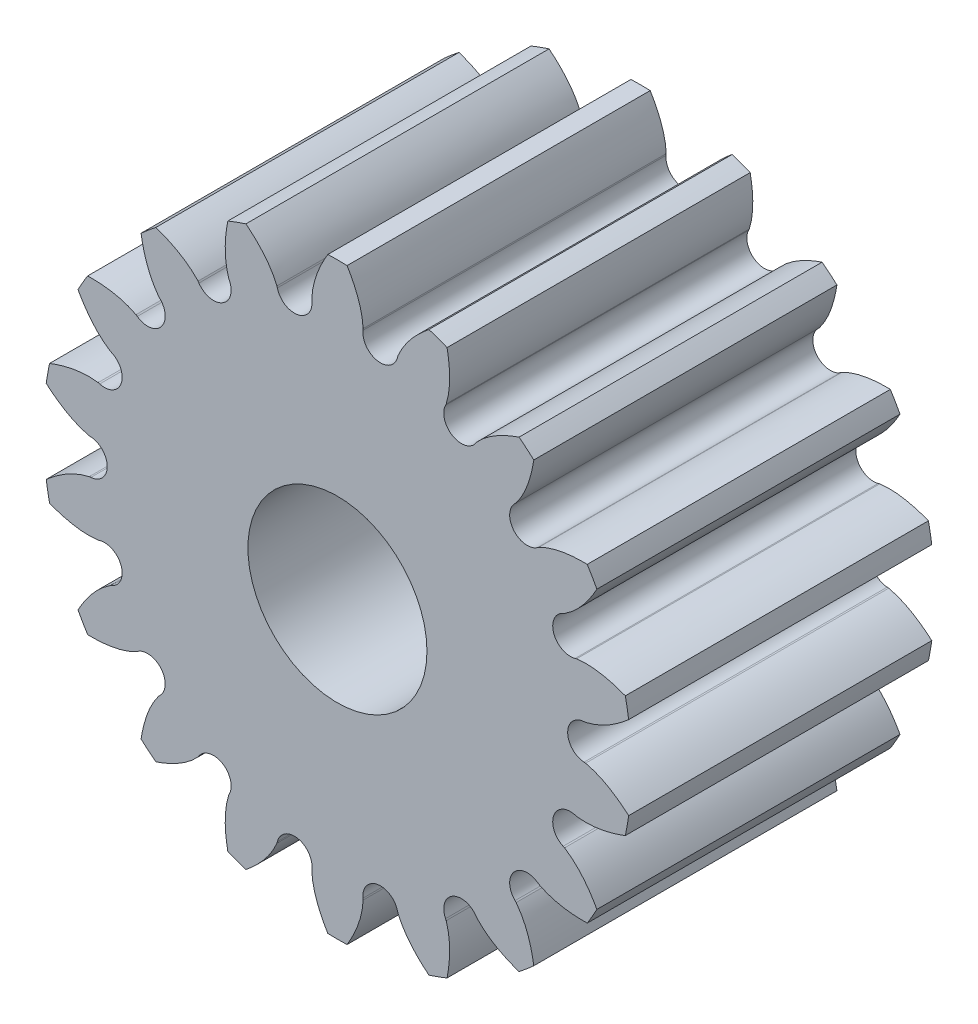
from build123d import *

# Parameters (mm, degrees)
SKETCH3_R                      = 2.286
SKETCH3_R_2                    = 0.889
BASE_DEPTH                     = 3.0099
HALF_TOOTH_DEPTH               = 3.0099
PATTERN_OF_TOOTH_COUNT         = 18
PATTERN_OF_TOOTH_COPY_1_DEPTH  = 3.0099
PATTERN_OF_TOOTH_COPY_2_DEPTH  = 3.0099
PATTERN_OF_TOOTH_COPY_3_DEPTH  = 3.0099
PATTERN_OF_TOOTH_COPY_4_DEPTH  = 3.0099
PATTERN_OF_TOOTH_COPY_5_DEPTH  = 3.0099
PATTERN_OF_TOOTH_COPY_6_DEPTH  = 3.0099
PATTERN_OF_TOOTH_COPY_7_DEPTH  = 3.0099
PATTERN_OF_TOOTH_COPY_8_DEPTH  = 3.0099
PATTERN_OF_TOOTH_COPY_9_DEPTH  = 3.0099
PATTERN_OF_TOOTH_COPY_10_DEPTH = 3.0099
PATTERN_OF_TOOTH_COPY_11_DEPTH = 3.0099
PATTERN_OF_TOOTH_COPY_12_DEPTH = 3.0099
PATTERN_OF_TOOTH_COPY_13_DEPTH = 3.0099
PATTERN_OF_TOOTH_COPY_14_DEPTH = 3.0099
PATTERN_OF_TOOTH_COPY_15_DEPTH = 3.0099
PATTERN_OF_TOOTH_COPY_16_DEPTH = 3.0099
PATTERN_OF_TOOTH_COPY_17_DEPTH = 3.0099


with BuildPart() as part:
    # Sketch3 → Base (new body)
    with BuildSketch(Plane.XY):
        Circle(SKETCH3_R)
        Circle(SKETCH3_R_2, mode=Mode.SUBTRACT)
    extrude(amount=BASE_DEPTH)

    # Sketch2 → Half tooth (add)
    with BuildSketch(Plane.XY):
        with BuildLine():
            Line((0, 2.921), (0, 2.286))
            ThreePointArc((0, 2.286), (0.199238028, 2.27730108), (0.396959734, 2.251270523))
            ThreePointArc((0.396959734, 2.251270523), (0.28773176, 2.318156306), (0.253382626, 2.441544292))
            Line((0.253382626, 2.441544292), (0.255003353, 2.457161288))
            add(Edge.make_bspline(
                [(0.255003353, 2.457161288), (0.25245669, 2.511970923), (0.22493294, 2.674677864), (0.152013752, 2.825486334), (0.095650308, 2.91943351)],
                knots=[0, 0, 0, 0, 0.332628043, 1, 1, 1, 1], degree=3))
            ThreePointArc((0.095650308, 2.91943351), (0.047831567, 2.920608351), (0, 2.921))
        make_face()
    half_tooth = extrude(amount=HALF_TOOTH_DEPTH)

    # Mirror of half tooth: Half tooth across plane
    add(half_tooth.mirror(Plane.ZY))

    # Pattern of tooth: Half tooth ×18 about axis
    pattern_of_tooth_axis = Axis((0, 0, 3.0099), (0, 0, 1))
    for i in range(1, PATTERN_OF_TOOTH_COUNT):
        add(half_tooth.rotate(pattern_of_tooth_axis, i * 360 / PATTERN_OF_TOOTH_COUNT))

    # Pattern of tooth copy 1 sketch → Pattern of tooth copy 1 (add)
    with BuildSketch(Plane(origin=(0, 0, 0), x_dir=(-0.939692621, -0.342020143, 0), z_dir=(0, 0, 1))):
        with BuildLine():
            Line((0, -2.921), (0, -2.286))
            ThreePointArc((0, -2.286), (0.199238028, -2.27730108), (0.396959734, -2.251270523))
            ThreePointArc((0.396959734, -2.251270523), (0.28773176, -2.318156306), (0.253382626, -2.441544292))
            Line((0.253382626, -2.441544292), (0.255003353, -2.457161288))
            add(Edge.make_bspline(
                [(0.255003353, -2.457161288), (0.25245669, -2.511970923), (0.22493294, -2.674677864), (0.152013752, -2.825486334), (0.095650308, -2.91943351)],
                knots=[0, 0, 0, 0, 0.332628043, 1, 1, 1, 1], degree=3))
            ThreePointArc((0.095650308, -2.91943351), (0.047831567, -2.920608351), (0, -2.921))
        make_face()
    extrude(amount=PATTERN_OF_TOOTH_COPY_1_DEPTH)

    # Pattern of tooth copy 2 sketch → Pattern of tooth copy 2 (add)
    with BuildSketch(Plane(origin=(0, 0, 0), x_dir=(-0.766044443, -0.64278761, 0), z_dir=(0, 0, 1))):
        with BuildLine():
            Line((0, -2.921), (0, -2.286))
            ThreePointArc((0, -2.286), (0.199238028, -2.27730108), (0.396959734, -2.251270523))
            ThreePointArc((0.396959734, -2.251270523), (0.28773176, -2.318156306), (0.253382626, -2.441544292))
            Line((0.253382626, -2.441544292), (0.255003353, -2.457161288))
            add(Edge.make_bspline(
                [(0.255003353, -2.457161288), (0.25245669, -2.511970923), (0.22493294, -2.674677864), (0.152013752, -2.825486334), (0.095650308, -2.91943351)],
                knots=[0, 0, 0, 0, 0.332628043, 1, 1, 1, 1], degree=3))
            ThreePointArc((0.095650308, -2.91943351), (0.047831567, -2.920608351), (0, -2.921))
        make_face()
    extrude(amount=PATTERN_OF_TOOTH_COPY_2_DEPTH)

    # Pattern of tooth copy 3 sketch → Pattern of tooth copy 3 (add)
    with BuildSketch(Plane(origin=(0, 0, 0), x_dir=(-0.5, -0.866025404, 0), z_dir=(0, 0, 1))):
        with BuildLine():
            Line((0, -2.921), (0, -2.286))
            ThreePointArc((0, -2.286), (0.199238028, -2.27730108), (0.396959734, -2.251270523))
            ThreePointArc((0.396959734, -2.251270523), (0.28773176, -2.318156306), (0.253382626, -2.441544292))
            Line((0.253382626, -2.441544292), (0.255003353, -2.457161288))
            add(Edge.make_bspline(
                [(0.255003353, -2.457161288), (0.25245669, -2.511970923), (0.22493294, -2.674677864), (0.152013752, -2.825486334), (0.095650308, -2.91943351)],
                knots=[0, 0, 0, 0, 0.332628043, 1, 1, 1, 1], degree=3))
            ThreePointArc((0.095650308, -2.91943351), (0.047831567, -2.920608351), (0, -2.921))
        make_face()
    extrude(amount=PATTERN_OF_TOOTH_COPY_3_DEPTH)

    # Pattern of tooth copy 4 sketch → Pattern of tooth copy 4 (add)
    with BuildSketch(Plane(origin=(0, 0, 0), x_dir=(-0.173648178, -0.984807753, 0), z_dir=(0, 0, 1))):
        with BuildLine():
            Line((0, -2.921), (0, -2.286))
            ThreePointArc((0, -2.286), (0.199238028, -2.27730108), (0.396959734, -2.251270523))
            ThreePointArc((0.396959734, -2.251270523), (0.28773176, -2.318156306), (0.253382626, -2.441544292))
            Line((0.253382626, -2.441544292), (0.255003353, -2.457161288))
            add(Edge.make_bspline(
                [(0.255003353, -2.457161288), (0.25245669, -2.511970923), (0.22493294, -2.674677864), (0.152013752, -2.825486334), (0.095650308, -2.91943351)],
                knots=[0, 0, 0, 0, 0.332628043, 1, 1, 1, 1], degree=3))
            ThreePointArc((0.095650308, -2.91943351), (0.047831567, -2.920608351), (0, -2.921))
        make_face()
    extrude(amount=PATTERN_OF_TOOTH_COPY_4_DEPTH)

    # Pattern of tooth copy 5 sketch → Pattern of tooth copy 5 (add)
    with BuildSketch(Plane(origin=(0, 0, 0), x_dir=(0.173648178, -0.984807753, 0), z_dir=(0, 0, 1))):
        with BuildLine():
            Line((0, -2.921), (0, -2.286))
            ThreePointArc((0, -2.286), (0.199238028, -2.27730108), (0.396959734, -2.251270523))
            ThreePointArc((0.396959734, -2.251270523), (0.28773176, -2.318156306), (0.253382626, -2.441544292))
            Line((0.253382626, -2.441544292), (0.255003353, -2.457161288))
            add(Edge.make_bspline(
                [(0.255003353, -2.457161288), (0.25245669, -2.511970923), (0.22493294, -2.674677864), (0.152013752, -2.825486334), (0.095650308, -2.91943351)],
                knots=[0, 0, 0, 0, 0.332628043, 1, 1, 1, 1], degree=3))
            ThreePointArc((0.095650308, -2.91943351), (0.047831567, -2.920608351), (0, -2.921))
        make_face()
    extrude(amount=PATTERN_OF_TOOTH_COPY_5_DEPTH)

    # Pattern of tooth copy 6 sketch → Pattern of tooth copy 6 (add)
    with BuildSketch(Plane(origin=(0, 0, 0), x_dir=(0.5, -0.866025404, 0), z_dir=(0, 0, 1))):
        with BuildLine():
            Line((0, -2.921), (0, -2.286))
            ThreePointArc((0, -2.286), (0.199238028, -2.27730108), (0.396959734, -2.251270523))
            ThreePointArc((0.396959734, -2.251270523), (0.28773176, -2.318156306), (0.253382626, -2.441544292))
            Line((0.253382626, -2.441544292), (0.255003353, -2.457161288))
            add(Edge.make_bspline(
                [(0.255003353, -2.457161288), (0.25245669, -2.511970923), (0.22493294, -2.674677864), (0.152013752, -2.825486334), (0.095650308, -2.91943351)],
                knots=[0, 0, 0, 0, 0.332628043, 1, 1, 1, 1], degree=3))
            ThreePointArc((0.095650308, -2.91943351), (0.047831567, -2.920608351), (0, -2.921))
        make_face()
    extrude(amount=PATTERN_OF_TOOTH_COPY_6_DEPTH)

    # Pattern of tooth copy 7 sketch → Pattern of tooth copy 7 (add)
    with BuildSketch(Plane(origin=(0, 0, 0), x_dir=(0.766044443, -0.64278761, 0), z_dir=(0, 0, 1))):
        with BuildLine():
            Line((0, -2.921), (0, -2.286))
            ThreePointArc((0, -2.286), (0.199238028, -2.27730108), (0.396959734, -2.251270523))
            ThreePointArc((0.396959734, -2.251270523), (0.28773176, -2.318156306), (0.253382626, -2.441544292))
            Line((0.253382626, -2.441544292), (0.255003353, -2.457161288))
            add(Edge.make_bspline(
                [(0.255003353, -2.457161288), (0.25245669, -2.511970923), (0.22493294, -2.674677864), (0.152013752, -2.825486334), (0.095650308, -2.91943351)],
                knots=[0, 0, 0, 0, 0.332628043, 1, 1, 1, 1], degree=3))
            ThreePointArc((0.095650308, -2.91943351), (0.047831567, -2.920608351), (0, -2.921))
        make_face()
    extrude(amount=PATTERN_OF_TOOTH_COPY_7_DEPTH)

    # Pattern of tooth copy 8 sketch → Pattern of tooth copy 8 (add)
    with BuildSketch(Plane(origin=(0, 0, 0), x_dir=(0.939692621, -0.342020143, 0), z_dir=(0, 0, 1))):
        with BuildLine():
            Line((0, -2.921), (0, -2.286))
            ThreePointArc((0, -2.286), (0.199238028, -2.27730108), (0.396959734, -2.251270523))
            ThreePointArc((0.396959734, -2.251270523), (0.28773176, -2.318156306), (0.253382626, -2.441544292))
            Line((0.253382626, -2.441544292), (0.255003353, -2.457161288))
            add(Edge.make_bspline(
                [(0.255003353, -2.457161288), (0.25245669, -2.511970923), (0.22493294, -2.674677864), (0.152013752, -2.825486334), (0.095650308, -2.91943351)],
                knots=[0, 0, 0, 0, 0.332628043, 1, 1, 1, 1], degree=3))
            ThreePointArc((0.095650308, -2.91943351), (0.047831567, -2.920608351), (0, -2.921))
        make_face()
    extrude(amount=PATTERN_OF_TOOTH_COPY_8_DEPTH)

    # Pattern of tooth copy 9 sketch → Pattern of tooth copy 9 (add)
    with BuildSketch(Plane.XY):
        with BuildLine():
            Line((0, -2.921), (0, -2.286))
            ThreePointArc((0, -2.286), (0.199238028, -2.27730108), (0.396959734, -2.251270523))
            ThreePointArc((0.396959734, -2.251270523), (0.28773176, -2.318156306), (0.253382626, -2.441544292))
            Line((0.253382626, -2.441544292), (0.255003353, -2.457161288))
            add(Edge.make_bspline(
                [(0.255003353, -2.457161288), (0.25245669, -2.511970923), (0.22493294, -2.674677864), (0.152013752, -2.825486334), (0.095650308, -2.91943351)],
                knots=[0, 0, 0, 0, 0.332628043, 1, 1, 1, 1], degree=3))
            ThreePointArc((0.095650308, -2.91943351), (0.047831567, -2.920608351), (0, -2.921))
        make_face()
    extrude(amount=PATTERN_OF_TOOTH_COPY_9_DEPTH)

    # Pattern of tooth copy 10 sketch → Pattern of tooth copy 10 (add)
    with BuildSketch(Plane(origin=(0, 0, 0), x_dir=(0.939692621, 0.342020143, 0), z_dir=(0, 0, 1))):
        with BuildLine():
            Line((0, -2.921), (0, -2.286))
            ThreePointArc((0, -2.286), (0.199238028, -2.27730108), (0.396959734, -2.251270523))
            ThreePointArc((0.396959734, -2.251270523), (0.28773176, -2.318156306), (0.253382626, -2.441544292))
            Line((0.253382626, -2.441544292), (0.255003353, -2.457161288))
            add(Edge.make_bspline(
                [(0.255003353, -2.457161288), (0.25245669, -2.511970923), (0.22493294, -2.674677864), (0.152013752, -2.825486334), (0.095650308, -2.91943351)],
                knots=[0, 0, 0, 0, 0.332628043, 1, 1, 1, 1], degree=3))
            ThreePointArc((0.095650308, -2.91943351), (0.047831567, -2.920608351), (0, -2.921))
        make_face()
    extrude(amount=PATTERN_OF_TOOTH_COPY_10_DEPTH)

    # Pattern of tooth copy 11 sketch → Pattern of tooth copy 11 (add)
    with BuildSketch(Plane(origin=(0, 0, 0), x_dir=(0.766044443, 0.64278761, 0), z_dir=(0, 0, 1))):
        with BuildLine():
            Line((0, -2.921), (0, -2.286))
            ThreePointArc((0, -2.286), (0.199238028, -2.27730108), (0.396959734, -2.251270523))
            ThreePointArc((0.396959734, -2.251270523), (0.28773176, -2.318156306), (0.253382626, -2.441544292))
            Line((0.253382626, -2.441544292), (0.255003353, -2.457161288))
            add(Edge.make_bspline(
                [(0.255003353, -2.457161288), (0.25245669, -2.511970923), (0.22493294, -2.674677864), (0.152013752, -2.825486334), (0.095650308, -2.91943351)],
                knots=[0, 0, 0, 0, 0.332628043, 1, 1, 1, 1], degree=3))
            ThreePointArc((0.095650308, -2.91943351), (0.047831567, -2.920608351), (0, -2.921))
        make_face()
    extrude(amount=PATTERN_OF_TOOTH_COPY_11_DEPTH)

    # Pattern of tooth copy 12 sketch → Pattern of tooth copy 12 (add)
    with BuildSketch(Plane(origin=(0, 0, 0), x_dir=(0.5, 0.866025404, 0), z_dir=(0, 0, 1))):
        with BuildLine():
            Line((0, -2.921), (0, -2.286))
            ThreePointArc((0, -2.286), (0.199238028, -2.27730108), (0.396959734, -2.251270523))
            ThreePointArc((0.396959734, -2.251270523), (0.28773176, -2.318156306), (0.253382626, -2.441544292))
            Line((0.253382626, -2.441544292), (0.255003353, -2.457161288))
            add(Edge.make_bspline(
                [(0.255003353, -2.457161288), (0.25245669, -2.511970923), (0.22493294, -2.674677864), (0.152013752, -2.825486334), (0.095650308, -2.91943351)],
                knots=[0, 0, 0, 0, 0.332628043, 1, 1, 1, 1], degree=3))
            ThreePointArc((0.095650308, -2.91943351), (0.047831567, -2.920608351), (0, -2.921))
        make_face()
    extrude(amount=PATTERN_OF_TOOTH_COPY_12_DEPTH)

    # Pattern of tooth copy 13 sketch → Pattern of tooth copy 13 (add)
    with BuildSketch(Plane(origin=(0, 0, 0), x_dir=(0.173648178, 0.984807753, 0), z_dir=(0, 0, 1))):
        with BuildLine():
            Line((0, -2.921), (0, -2.286))
            ThreePointArc((0, -2.286), (0.199238028, -2.27730108), (0.396959734, -2.251270523))
            ThreePointArc((0.396959734, -2.251270523), (0.28773176, -2.318156306), (0.253382626, -2.441544292))
            Line((0.253382626, -2.441544292), (0.255003353, -2.457161288))
            add(Edge.make_bspline(
                [(0.255003353, -2.457161288), (0.25245669, -2.511970923), (0.22493294, -2.674677864), (0.152013752, -2.825486334), (0.095650308, -2.91943351)],
                knots=[0, 0, 0, 0, 0.332628043, 1, 1, 1, 1], degree=3))
            ThreePointArc((0.095650308, -2.91943351), (0.047831567, -2.920608351), (0, -2.921))
        make_face()
    extrude(amount=PATTERN_OF_TOOTH_COPY_13_DEPTH)

    # Pattern of tooth copy 14 sketch → Pattern of tooth copy 14 (add)
    with BuildSketch(Plane(origin=(0, 0, 0), x_dir=(-0.173648178, 0.984807753, 0), z_dir=(0, 0, 1))):
        with BuildLine():
            Line((0, -2.921), (0, -2.286))
            ThreePointArc((0, -2.286), (0.199238028, -2.27730108), (0.396959734, -2.251270523))
            ThreePointArc((0.396959734, -2.251270523), (0.28773176, -2.318156306), (0.253382626, -2.441544292))
            Line((0.253382626, -2.441544292), (0.255003353, -2.457161288))
            add(Edge.make_bspline(
                [(0.255003353, -2.457161288), (0.25245669, -2.511970923), (0.22493294, -2.674677864), (0.152013752, -2.825486334), (0.095650308, -2.91943351)],
                knots=[0, 0, 0, 0, 0.332628043, 1, 1, 1, 1], degree=3))
            ThreePointArc((0.095650308, -2.91943351), (0.047831567, -2.920608351), (0, -2.921))
        make_face()
    extrude(amount=PATTERN_OF_TOOTH_COPY_14_DEPTH)

    # Pattern of tooth copy 15 sketch → Pattern of tooth copy 15 (add)
    with BuildSketch(Plane(origin=(0, 0, 0), x_dir=(-0.5, 0.866025404, 0), z_dir=(0, 0, 1))):
        with BuildLine():
            Line((0, -2.921), (0, -2.286))
            ThreePointArc((0, -2.286), (0.199238028, -2.27730108), (0.396959734, -2.251270523))
            ThreePointArc((0.396959734, -2.251270523), (0.28773176, -2.318156306), (0.253382626, -2.441544292))
            Line((0.253382626, -2.441544292), (0.255003353, -2.457161288))
            add(Edge.make_bspline(
                [(0.255003353, -2.457161288), (0.25245669, -2.511970923), (0.22493294, -2.674677864), (0.152013752, -2.825486334), (0.095650308, -2.91943351)],
                knots=[0, 0, 0, 0, 0.332628043, 1, 1, 1, 1], degree=3))
            ThreePointArc((0.095650308, -2.91943351), (0.047831567, -2.920608351), (0, -2.921))
        make_face()
    extrude(amount=PATTERN_OF_TOOTH_COPY_15_DEPTH)

    # Pattern of tooth copy 16 sketch → Pattern of tooth copy 16 (add)
    with BuildSketch(Plane(origin=(0, 0, 0), x_dir=(-0.766044443, 0.64278761, 0), z_dir=(0, 0, 1))):
        with BuildLine():
            Line((0, -2.921), (0, -2.286))
            ThreePointArc((0, -2.286), (0.199238028, -2.27730108), (0.396959734, -2.251270523))
            ThreePointArc((0.396959734, -2.251270523), (0.28773176, -2.318156306), (0.253382626, -2.441544292))
            Line((0.253382626, -2.441544292), (0.255003353, -2.457161288))
            add(Edge.make_bspline(
                [(0.255003353, -2.457161288), (0.25245669, -2.511970923), (0.22493294, -2.674677864), (0.152013752, -2.825486334), (0.095650308, -2.91943351)],
                knots=[0, 0, 0, 0, 0.332628043, 1, 1, 1, 1], degree=3))
            ThreePointArc((0.095650308, -2.91943351), (0.047831567, -2.920608351), (0, -2.921))
        make_face()
    extrude(amount=PATTERN_OF_TOOTH_COPY_16_DEPTH)

    # Pattern of tooth copy 17 sketch → Pattern of tooth copy 17 (add)
    with BuildSketch(Plane(origin=(0, 0, 0), x_dir=(-0.939692621, 0.342020143, 0), z_dir=(0, 0, 1))):
        with BuildLine():
            Line((0, -2.921), (0, -2.286))
            ThreePointArc((0, -2.286), (0.199238028, -2.27730108), (0.396959734, -2.251270523))
            ThreePointArc((0.396959734, -2.251270523), (0.28773176, -2.318156306), (0.253382626, -2.441544292))
            Line((0.253382626, -2.441544292), (0.255003353, -2.457161288))
            add(Edge.make_bspline(
                [(0.255003353, -2.457161288), (0.25245669, -2.511970923), (0.22493294, -2.674677864), (0.152013752, -2.825486334), (0.095650308, -2.91943351)],
                knots=[0, 0, 0, 0, 0.332628043, 1, 1, 1, 1], degree=3))
            ThreePointArc((0.095650308, -2.91943351), (0.047831567, -2.920608351), (0, -2.921))
        make_face()
    extrude(amount=PATTERN_OF_TOOTH_COPY_17_DEPTH)


solid = part.part
